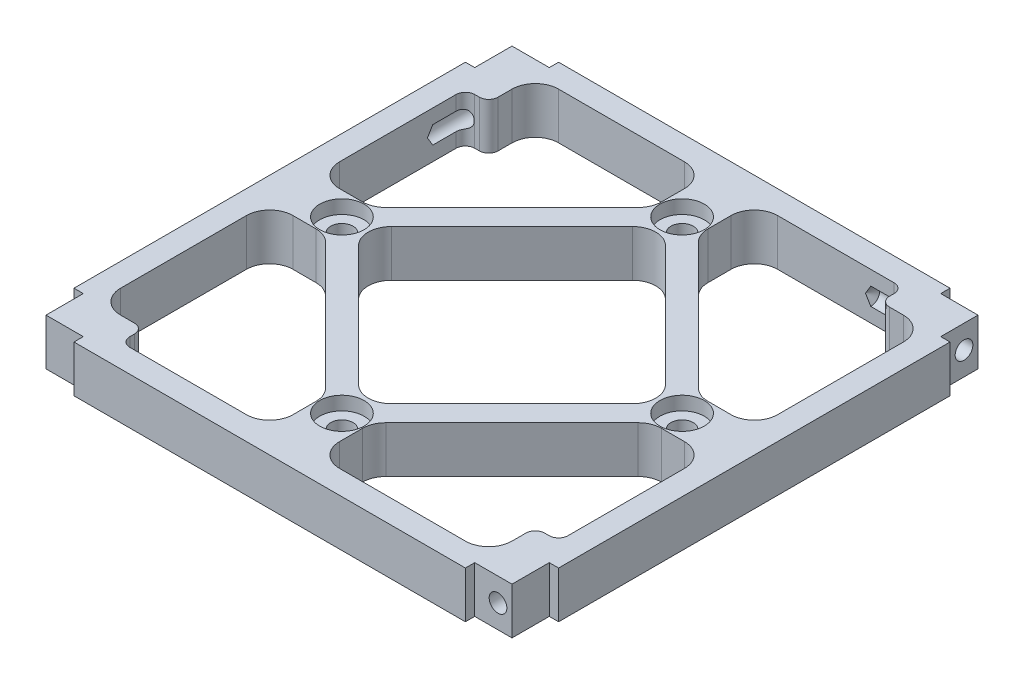
from build123d import *

# Parameters (mm, degrees)
SKETCH1_W                                           = 104
SKETCH1_H                                           = 104
BOSS_EXTRUDE1_DEPTH                                 = 10
FILLET1_R                                           = 5
CUT_EXTRUDE1_DEPTH                                  = 11
CIRPATTERN1_COUNT                                   = 4
CBORE_FOR_12_BINDING_HEAD_MACHINE_SCREW_D           = 4.8006
CBORE_FOR_12_BINDING_HEAD_MACHINE_SCREW_CBORE_D     = 9.525
CBORE_FOR_12_BINDING_HEAD_MACHINE_SCREW_CBORE_DEPTH = 2.921
FILLET3_R                                           = 2
CIRPATTERN5_COUNT                                   = 4


with BuildPart() as part:
    # Sketch1 → Boss-Extrude1 (new body)
    with BuildSketch(Plane(origin=(0, 0, 0), x_dir=(1, 0, 0), z_dir=(0, 1, 0))):
        Rectangle(SKETCH1_W, SKETCH1_H)
        Polygon((-42, 47), (-42, 37), (-47, 37), (-47, 5), (-35, 5), (-5, 35), (-5, 47), align=None, mode=Mode.SUBTRACT)
        Polygon((-32.928932188, 0), (0, 32.928932188), (32.928932188, 0), (0, -32.928932188), align=None, mode=Mode.SUBTRACT)
        Polygon((5, 47), (5, 35), (35, 5), (47, 5), (47, 42), (37, 42), (37, 47), align=None, mode=Mode.SUBTRACT)
        Polygon((47, -5), (35, -5), (5, -35), (5, -47), (42, -47), (42, -37), (47, -37), align=None, mode=Mode.SUBTRACT)
        Polygon((-5, -47), (-5, -35), (-35, -5), (-47, -5), (-47, -42), (-37, -42), (-37, -47), align=None, mode=Mode.SUBTRACT)
    extrude(amount=BOSS_EXTRUDE1_DEPTH)

    # Fillet1
    fillet1_edges = [part.edges().sort_by_distance(p)[0] for p in [
        (-5, 5, -35),
        (-5, 5, -47),
        (-42, 5, -47),
        (-47, 5, -5),
        (-35, 5, -5),
        (-32.928932188, 5, 0),
        (0, 5, 32.928932188),
        (32.928932188, 5, 0),
        (0, 5, -32.928932188),
        (5, 5, -35),
        (35, 5, -5),
        (47, 5, -5),
        (47, 5, -42),
        (5, 5, -47),
        (35, 5, 5),
        (5, 5, 35),
        (5, 5, 47),
        (42, 5, 47),
        (47, 5, 5),
        (-5, 5, 35),
        (-35, 5, 5),
        (-47, 5, 5),
        (-47, 5, 42),
        (-5, 5, 47),
    ]]
    fillet(fillet1_edges, radius=FILLET1_R)

    # Sketch2 → Cut-Extrude1 (cut, through all)
    with BuildSketch(Plane(origin=(0, 10, 0), x_dir=(1, 0, 0), z_dir=(0, 1, 0))):
        Polygon((-52, 52), (-42, 52), (-42, 50), (-50, 50), (-50, 42), (-52, 42), align=None)
    cut_extrude1 = extrude(amount=-CUT_EXTRUDE1_DEPTH, mode=Mode.SUBTRACT)

    # CirPattern1: Cut-Extrude1 ×4 about axis
    cirpattern1_axis = Axis((0, 0, 0), (0, 1, 0))
    for i in range(1, CIRPATTERN1_COUNT):
        add(cut_extrude1.rotate(cirpattern1_axis, i * 360 / CIRPATTERN1_COUNT), mode=Mode.SUBTRACT)

    # CBORE for #12 Binding Head Machine Screw1 (through all)
    with Locations(Plane(origin=(0, 10, 0), x_dir=(1, 0, 0), z_dir=(0, 1, 0))):
        with Locations((0, 36.5), (-36.5, 0), (0, -36.5), (36.5, 0)):
            CounterBoreHole(CBORE_FOR_12_BINDING_HEAD_MACHINE_SCREW_D / 2, CBORE_FOR_12_BINDING_HEAD_MACHINE_SCREW_CBORE_D / 2, CBORE_FOR_12_BINDING_HEAD_MACHINE_SCREW_CBORE_DEPTH)

    # Fillet3
    fillet3_edges = [part.edges().sort_by_distance(p)[0] for p in [
        (-42, 5, -37),
        (-47, 5, -37),
        (37, 5, -42),
        (37, 5, -47),
        (42, 5, 37),
        (47, 5, 37),
        (-37, 5, 42),
        (-37, 5, 47),
    ]]
    fillet(fillet3_edges, radius=FILLET3_R)

    # Sketch9 → #10-24 Tapped Hole1 (revolve, cut)
    with BuildSketch(Plane(origin=(50, 5, -47), x_dir=(0, 0, -1), z_dir=(0, 1, 0))):
        Polygon((0, 0), (0, 21.140824014), (1.89865, 20), (1.89865, 0), align=None)
    f_10_24_tapped_hole1 = revolve(axis=Axis((56.35, 5, -47), (-1, 0, 0)), mode=Mode.SUBTRACT)

    # CirPattern5: #10-24 Tapped Hole1 ×4 about axis
    cirpattern5_axis = Axis((0, 10.5, 0), (0, -1, 0))
    for i in range(1, CIRPATTERN5_COUNT):
        add(f_10_24_tapped_hole1.rotate(cirpattern5_axis, i * 360 / CIRPATTERN5_COUNT), mode=Mode.SUBTRACT)


solid = part.part
